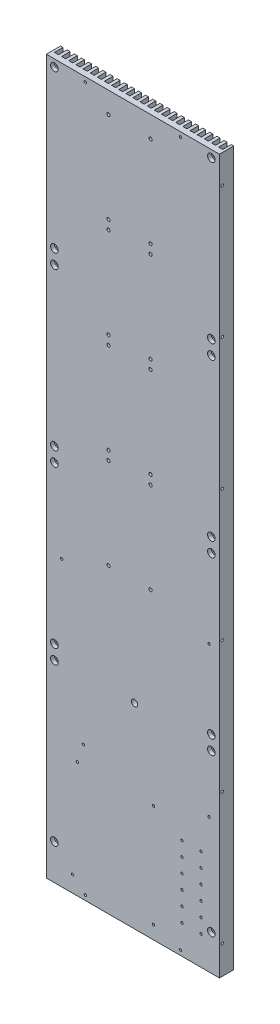
from build123d import *

# Parameters (mm, degrees)
SKETCH_2_W                   = 182
SKETCH_2_H                   = 15
EXTRUDE_1_DEPTH              = 750
SKETCH_3_W                   = 4.3
SKETCH_3_H                   = 9
CUT_EXTRUDE_1_DEPTH          = 751
PATTERN_LINEAR_1_COUNT       = 12
PATTERN_LINEAR_1_PITCH       = 7.5
PATTERN_LINEAR_1_COL_COUNT   = 13
PATTERN_LINEAR_1_COL_PITCH   = 7.5
HOLE_WIZARD_M3_3_AT_2_COUNT  = 2
HOLE_WIZARD_M3_3_AT_2_PITCH  = 138
HOLE_WIZARD_M3_3_AT_3_COUNT  = 2
HOLE_WIZARD_M3_3_AT_3_PITCH  = 276
HOLE_WIZARD_M3_3_AT_4_COUNT  = 2
HOLE_WIZARD_M3_3_AT_4_PITCH  = 414
HOLE_WIZARD_M3_3_AT_5_COUNT  = 2
HOLE_WIZARD_M3_3_AT_5_PITCH  = 552
HOLE_WIZARD_M3_3_AT_6_COUNT  = 2
HOLE_WIZARD_M3_3_AT_6_PITCH  = 690
HOLE_WIZARD_M3_1_D           = 3.4
HOLE_WIZARD_M3_1_CBORE_D     = 6.5
HOLE_WIZARD_M3_1_CBORE_DEPTH = 12
PATTERN_LINEAR_2_COUNT       = 4
PATTERN_LINEAR_2_PITCH       = 105
HOLE_WIZARD_M3_4_D           = 2.5
HOLE_WIZARD_M6_1_D           = 6.6
HOLE_WIZARD_M6_1_DEPTH       = 17
HOLE_WIZARD_M6_1_CBORE_D     = 11
HOLE_WIZARD_M6_1_CBORE_DEPTH = 10
HOLE_WIZARD_M6_1_TIP         = 1.982840043
HOLE_WIZARD_M3_5_D           = 2.5
HOLE_WIZARD_M3_5_DEPTH       = 8.5
HOLE_WIZARD_M3_5_TIP         = 0.751075774
HOLE_WIZARD_M3_6_D           = 2.5
HOLE_WIZARD_M3_6_DEPTH       = 10.5
HOLE_WIZARD_M3_6_TIP         = 0.751075774
HOLE_WIZARD_M3_9_D           = 2.5
HOLE_WIZARD_M3_9_DEPTH       = 10.5
HOLE_WIZARD_M3_9_TIP         = 0.751075774
HOLE_WIZARD_M4_1_D           = 4.5
HOLE_WIZARD_M4_1_CBORE_D     = 8
HOLE_WIZARD_M4_1_CBORE_DEPTH = 4
PATTERN_LINEAR_3_COUNT       = 4
PATTERN_LINEAR_3_PITCH       = 180


with BuildPart() as part:
    # 스케치2 → 보스-돌출1 (new body)
    with BuildSketch(Plane(origin=(0, 0, 0), x_dir=(1, 0, 0), z_dir=(0, 1, 0))):
        with Locations((0, 7.5)):
            Rectangle(SKETCH_2_W, SKETCH_2_H)
    extrude(amount=EXTRUDE_1_DEPTH)

    # 스케치3 → 컷-돌출1 (cut, through all)
    with BuildSketch(Plane(origin=(0, 0, 0), x_dir=(1, 0, 0), z_dir=(0, 1, 0))):
        with Locations((3.75, 10.5)):
            Rectangle(SKETCH_3_W, SKETCH_3_H)
    cut_extrude_1 = extrude(amount=CUT_EXTRUDE_1_DEPTH, mode=Mode.SUBTRACT)

    # 선형 패턴1: 컷-돌출1 ×12
    with Locations(*[(i * PATTERN_LINEAR_1_PITCH, 0, 0) for i in range(1, PATTERN_LINEAR_1_COUNT)]):
        add(cut_extrude_1, mode=Mode.SUBTRACT)

    # 선형 패턴1 col: 컷-돌출1 ×13
    with Locations(*[(-i * PATTERN_LINEAR_1_COL_PITCH, 0, 0) for i in range(1, PATTERN_LINEAR_1_COL_COUNT)]):
        add(cut_extrude_1, mode=Mode.SUBTRACT)

    # 스케치8 → M3 나사 구멍3 (revolve, cut)
    with BuildSketch(Plane(origin=(91, 720, -3), x_dir=(0, 0, -1), z_dir=(0, 1, 0))):
        Polygon((0, 0), (0, 10.751075774), (1.25, 10), (1.25, 0), align=None)
    hole_wizard_m3_3 = revolve(axis=Axis((97.35, 720, -3), (-1, 0, 0)), mode=Mode.SUBTRACT)

    # M3 나사 구멍3 at 2: M3 나사 구멍3 ×2
    with Locations(*[(0, -i * HOLE_WIZARD_M3_3_AT_2_PITCH, 0) for i in range(1, HOLE_WIZARD_M3_3_AT_2_COUNT)]):
        add(hole_wizard_m3_3, mode=Mode.SUBTRACT)

    # M3 나사 구멍3 at 3: M3 나사 구멍3 ×2
    with Locations(*[(0, -i * HOLE_WIZARD_M3_3_AT_3_PITCH, 0) for i in range(1, HOLE_WIZARD_M3_3_AT_3_COUNT)]):
        add(hole_wizard_m3_3, mode=Mode.SUBTRACT)

    # M3 나사 구멍3 at 4: M3 나사 구멍3 ×2
    with Locations(*[(0, -i * HOLE_WIZARD_M3_3_AT_4_PITCH, 0) for i in range(1, HOLE_WIZARD_M3_3_AT_4_COUNT)]):
        add(hole_wizard_m3_3, mode=Mode.SUBTRACT)

    # M3 나사 구멍3 at 5: M3 나사 구멍3 ×2
    with Locations(*[(0, -i * HOLE_WIZARD_M3_3_AT_5_PITCH, 0) for i in range(1, HOLE_WIZARD_M3_3_AT_5_COUNT)]):
        add(hole_wizard_m3_3, mode=Mode.SUBTRACT)

    # M3 나사 구멍3 at 6: M3 나사 구멍3 ×2
    with Locations(*[(0, -i * HOLE_WIZARD_M3_3_AT_6_PITCH, 0) for i in range(1, HOLE_WIZARD_M3_3_AT_6_COUNT)]):
        add(hole_wizard_m3_3, mode=Mode.SUBTRACT)

    # 대칭 복사1: M3 나사 구멍3 across plane
    add(hole_wizard_m3_3.mirror(Plane(origin=(0, 0, 0), x_dir=(0, 0, 1), z_dir=(1, 0, 0))), mode=Mode.SUBTRACT)

    # 대칭 복사1 copy 1 sketch → 대칭 복사1 copy 1 (revolve, cut)
    with BuildSketch(Plane(origin=(-91, 582, -3), x_dir=(0, 0, -1), z_dir=(0, 1, 0))):
        Polygon((0, 0), (0, -10.751075774), (1.25, -10), (1.25, 0), align=None)
    revolve(axis=Axis((-97.35, 582, -3), (-1, 0, 0)), mode=Mode.SUBTRACT)

    # 대칭 복사1 copy 2 sketch → 대칭 복사1 copy 2 (revolve, cut)
    with BuildSketch(Plane(origin=(-91, 444, -3), x_dir=(0, 0, -1), z_dir=(0, 1, 0))):
        Polygon((0, 0), (0, -10.751075774), (1.25, -10), (1.25, 0), align=None)
    revolve(axis=Axis((-97.35, 444, -3), (-1, 0, 0)), mode=Mode.SUBTRACT)

    # 대칭 복사1 copy 3 sketch → 대칭 복사1 copy 3 (revolve, cut)
    with BuildSketch(Plane(origin=(-91, 306, -3), x_dir=(0, 0, -1), z_dir=(0, 1, 0))):
        Polygon((0, 0), (0, -10.751075774), (1.25, -10), (1.25, 0), align=None)
    revolve(axis=Axis((-97.35, 306, -3), (-1, 0, 0)), mode=Mode.SUBTRACT)

    # 대칭 복사1 copy 4 sketch → 대칭 복사1 copy 4 (revolve, cut)
    with BuildSketch(Plane(origin=(-91, 168, -3), x_dir=(0, 0, -1), z_dir=(0, 1, 0))):
        Polygon((0, 0), (0, -10.751075774), (1.25, -10), (1.25, 0), align=None)
    revolve(axis=Axis((-97.35, 168, -3), (-1, 0, 0)), mode=Mode.SUBTRACT)

    # 대칭 복사1 copy 5 sketch → 대칭 복사1 copy 5 (revolve, cut)
    with BuildSketch(Plane(origin=(-91, 30, -3), x_dir=(0, 0, -1), z_dir=(0, 1, 0))):
        Polygon((0, 0), (0, -10.751075774), (1.25, -10), (1.25, 0), align=None)
    revolve(axis=Axis((-97.35, 30, -3), (-1, 0, 0)), mode=Mode.SUBTRACT)

    # M3 소켓 머리 캡 나사용 카운터보어1 (through all)
    with Locations(Plane(origin=(0, 0, -15), x_dir=(-1, 0, 0), z_dir=(0, 0, -1))):
        with Locations((25.6, 317.25), (-18.6, 317.25), (25.6, 412.75), (-18.6, 412.75)):
            hole_wizard_m3_1 = CounterBoreHole(HOLE_WIZARD_M3_1_D / 2, HOLE_WIZARD_M3_1_CBORE_D / 2, HOLE_WIZARD_M3_1_CBORE_DEPTH)

    # 선형 패턴2: M3 소켓 머리 캡 나사용 카운터보어1 ×4
    with Locations(*[(0, i * PATTERN_LINEAR_2_PITCH, 0) for i in range(1, PATTERN_LINEAR_2_COUNT)]):
        add(hole_wizard_m3_1, mode=Mode.SUBTRACT)

    # M3 나사 구멍4 (through all)
    with Locations(Plane.XY):
        with Locations((-74.84, 298.65), (80.1, 298.65), (80.1, 141.17), (-51.98, 141.17)):
            Hole(HOLE_WIZARD_M3_4_D / 2)

    # M6 소켓 머리 캡 나사용 카운터보어1
    with Locations(Plane(origin=(0, 0, -15), x_dir=(-1, 0, 0), z_dir=(0, 0, -1))):
        with Locations((-1.75, 205.75)):
            CounterBoreHole(HOLE_WIZARD_M6_1_D / 2, HOLE_WIZARD_M6_1_CBORE_D / 2, HOLE_WIZARD_M6_1_CBORE_DEPTH, depth=HOLE_WIZARD_M6_1_DEPTH)
            with Locations((0, 0, -(HOLE_WIZARD_M6_1_DEPTH + HOLE_WIZARD_M6_1_TIP / 2))):  # 118° drill point
                Cone(0, HOLE_WIZARD_M6_1_D / 2, HOLE_WIZARD_M6_1_TIP, mode=Mode.SUBTRACT)

    # M3 나사 구멍5
    with Locations(Plane.XY):
        with Locations((-58.35, 122), (21.65, 122), (21.65, 14), (-63.35, 17)):
            Hole(HOLE_WIZARD_M3_5_D / 2, depth=HOLE_WIZARD_M3_5_DEPTH)
            with Locations((0, 0, -(HOLE_WIZARD_M3_5_DEPTH + HOLE_WIZARD_M3_5_TIP / 2))):  # 118° drill point
                Cone(0, HOLE_WIZARD_M3_5_D / 2, HOLE_WIZARD_M3_5_TIP, mode=Mode.SUBTRACT)

    # M3 나사 구멍6
    with Locations(Plane.XY):
        with Locations((51.65, 90.5), (71.65, 90.5), (71.65, 75.5), (71.65, 60.5), (71.65, 45.5), (51.65, 45.5), (51.65, 60.5), (51.65, 75.5), (51.65, 105.5), (71.65, 105.5), (71.65, 30.5), (51.65, 30.5)):
            Hole(HOLE_WIZARD_M3_6_D / 2, depth=HOLE_WIZARD_M3_6_DEPTH)
            with Locations((0, 0, -(HOLE_WIZARD_M3_6_DEPTH + HOLE_WIZARD_M3_6_TIP / 2))):  # 118° drill point
                Cone(0, HOLE_WIZARD_M3_6_D / 2, HOLE_WIZARD_M3_6_TIP, mode=Mode.SUBTRACT)

    # M3 나사 구멍9
    with Locations(Plane.XY):
        with Locations((-50, 745), (50, 745), (50, 5), (-50, 5)):
            Hole(HOLE_WIZARD_M3_9_D / 2, depth=HOLE_WIZARD_M3_9_DEPTH)
            with Locations((0, 0, -(HOLE_WIZARD_M3_9_DEPTH + HOLE_WIZARD_M3_9_TIP / 2))):  # 118° drill point
                Cone(0, HOLE_WIZARD_M3_9_D / 2, HOLE_WIZARD_M3_9_TIP, mode=Mode.SUBTRACT)

    # M4 소켓 머리 캡 나사용 카운터보어1 (through all)
    with Locations(Plane.XY):
        with Locations((82.5, 202.5), (82.5, 37.5), (-82.5, 37.5), (-82.5, 202.5)):
            hole_wizard_m4_1 = CounterBoreHole(HOLE_WIZARD_M4_1_D / 2, HOLE_WIZARD_M4_1_CBORE_D / 2, HOLE_WIZARD_M4_1_CBORE_DEPTH)

    # 선형 패턴3: M4 소켓 머리 캡 나사용 카운터보어1 ×4
    with Locations(*[(0, i * PATTERN_LINEAR_3_PITCH, 0) for i in range(1, PATTERN_LINEAR_3_COUNT)]):
        add(hole_wizard_m4_1, mode=Mode.SUBTRACT)


solid = part.part
